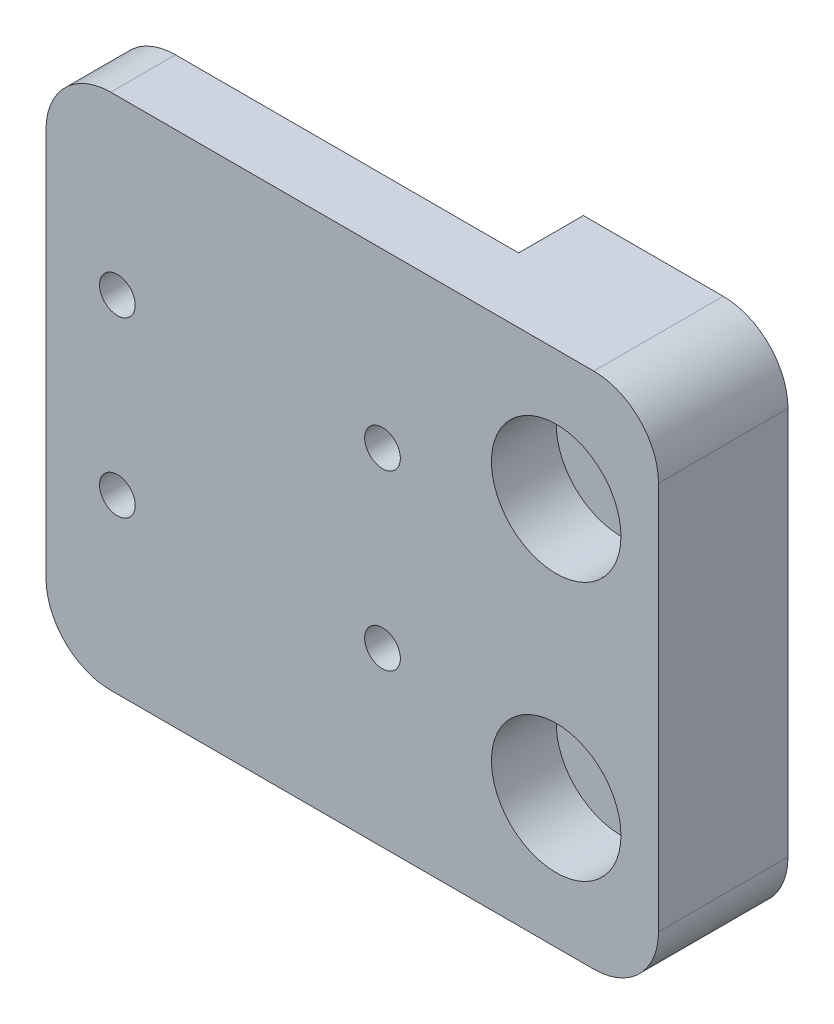
from build123d import *

# Parameters (mm, degrees)
SKETCH1_W           = 20.066
SKETCH1_H           = 50.8
BOSS_EXTRUDE1_DEPTH = 12.7
SKETCH2_R           = 2.286
CUT_EXTRUDE1_DEPTH  = 13.7
SKETCH3_W           = 40
SKETCH3_H           = 50.8
BOSS_EXTRUDE2_DEPTH = 6.35
SKETCH5_R           = 1.75
CUT_EXTRUDE2_DEPTH  = 7.35
SKETCH6_R           = 6.35
CUT_EXTRUDE3_DEPTH  = 6.35
FILLET1_R           = 6.35


with BuildPart() as part:
    # Sketch1 → Boss-Extrude1 (new body)
    with BuildSketch(Plane.XY):
        Rectangle(SKETCH1_W, SKETCH1_H)
    extrude(amount=BOSS_EXTRUDE1_DEPTH)

    # Sketch2 → Cut-Extrude1 (cut, through all)
    with BuildSketch(Plane.XY.offset(12.7)):
        with Locations((0, 12.7)):
            Circle(SKETCH2_R)
        with Locations((0, -12.7)):
            Circle(SKETCH2_R)
    extrude(amount=-CUT_EXTRUDE1_DEPTH, mode=Mode.SUBTRACT)

    # Sketch3 → Boss-Extrude2 (add)
    with BuildSketch(Plane.XY.offset(12.7)):
        with Locations((-30.033, 0)):
            Rectangle(SKETCH3_W, SKETCH3_H)
    extrude(amount=-BOSS_EXTRUDE2_DEPTH)

    # Sketch5 → Cut-Extrude2 (cut, through all)
    with BuildSketch(Plane(origin=(0, 0, 6.35), x_dir=(-1, 0, 0), z_dir=(0, 0, -1))):
        with Locations((43.033, 8.5)):
            Circle(SKETCH5_R)
        with Locations((17.033, 8.5)):
            Circle(SKETCH5_R)
        with Locations((43.033, -8.5)):
            Circle(SKETCH5_R)
        with Locations((17.033, -8.5)):
            Circle(SKETCH5_R)
    extrude(amount=-CUT_EXTRUDE2_DEPTH, mode=Mode.SUBTRACT)

    # Sketch6 → Cut-Extrude3 (cut)
    with BuildSketch(Plane.XY.offset(12.7)):
        with Locations((0, 12.7)):
            Circle(SKETCH6_R)
        with Locations((0, -12.7)):
            Circle(SKETCH6_R)
    extrude(amount=-CUT_EXTRUDE3_DEPTH, mode=Mode.SUBTRACT)

    # Fillet1
    fillet1_edges = [part.edges().sort_by_distance(p)[0] for p in [
        (-50.033, -25.4, 9.525),
        (-50.033, 25.4, 9.525),
        (10.033, -25.4, 6.35),
        (10.033, 25.4, 6.35),
    ]]
    fillet(fillet1_edges, radius=FILLET1_R)


solid = part.part
